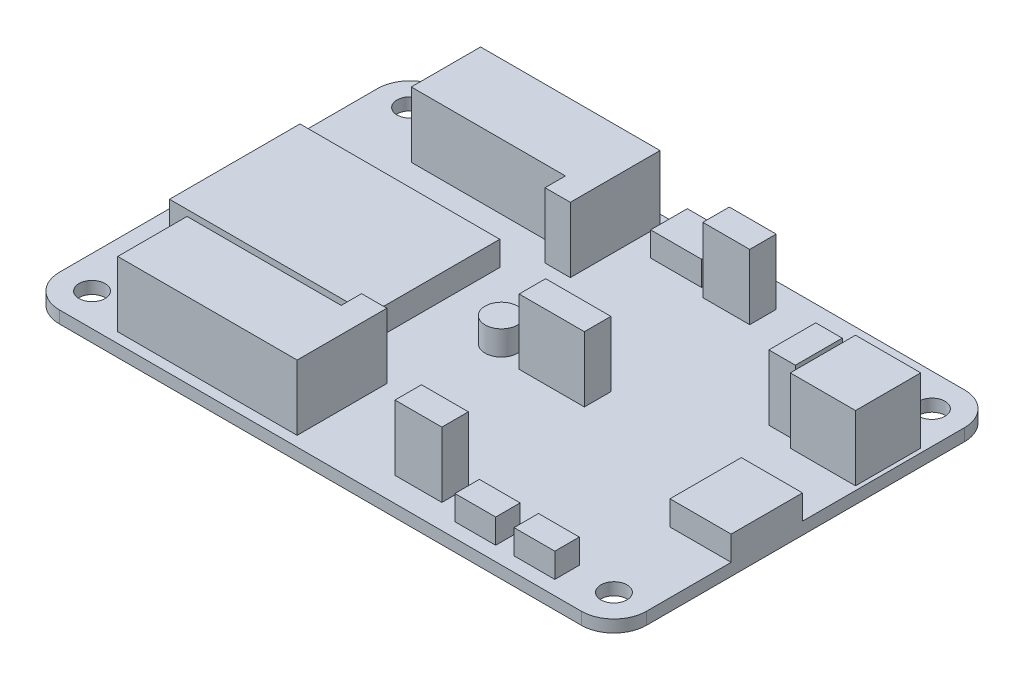
from build123d import *

# Parameters (mm, degrees)
CROQUIS1_W              = 72
CROQUIS1_H              = 47
SALIENTE_EXTRUIR1_DEPTH = 1.5
CROQUIS2_R              = 1.6
CORTAR_EXTRUIR1_DEPTH   = 2.5
REDONDEO1_R             = 4
CROQUIS3_W              = 5.75
CROQUIS3_H              = 3.25
CROQUIS3_W_2            = 3.25
CROQUIS3_H_2            = 5.75
CROQUIS3_W_3            = 8
CROQUIS3_H_3            = 8
SALIENTE_EXTRUIR2_DEPTH = 8
CROQUIS6_R              = 2
CROQUIS6_W              = 7.5
CROQUIS6_H              = 8.749690514
CROQUIS6_W_2            = 5
CROQUIS6_H_2            = 3
CROQUIS6_W_3            = 6.25
CROQUIS6_H_3            = 4.5
CROQUIS6_W_4            = 24.5
CROQUIS6_H_4            = 16
SALIENTE_EXTRUIR3_DEPTH = 3


with BuildPart() as part:
    # Croquis1 → Saliente-Extruir1 (new body)
    with BuildSketch(Plane(origin=(0, 0, 0), x_dir=(1, 0, 0), z_dir=(0, 1, 0))):
        Rectangle(CROQUIS1_W, CROQUIS1_H)
    extrude(amount=SALIENTE_EXTRUIR1_DEPTH)

    # Croquis2 → Cortar-Extruir1 (cut, through all)
    with BuildSketch(Plane(origin=(0, 1.5, 0), x_dir=(1, 0, 0), z_dir=(0, 1, 0))):
        with Locations((-32, 19.5)):
            Circle(CROQUIS2_R)
        with Locations((32, 19.5)):
            Circle(CROQUIS2_R)
        with Locations((32, -19.5)):
            Circle(CROQUIS2_R)
        with Locations((-32, -19.5)):
            Circle(CROQUIS2_R)
    extrude(amount=-CORTAR_EXTRUIR1_DEPTH, mode=Mode.SUBTRACT)

    # Redondeo1
    redondeo1_edges = [part.edges().sort_by_distance(p)[0] for p in [
        (36, 0.75, 23.5),
        (-36, 0.75, 23.5),
        (-36, 0.75, -23.5),
        (36, 0.75, -23.5),
    ]]
    fillet(redondeo1_edges, radius=REDONDEO1_R)

    # Croquis3 → Saliente-Extruir2 (add)
    with BuildSketch(Plane(origin=(0, 1.5, 0), x_dir=(1, 0, 0), z_dir=(0, 1, 0))):
        Polygon((-4.1, 11.25), (-7.2, 11.25), (-7.2, 13.75), (-26.1, 13.75), (-26.1, 22.25), (-4.1, 22.25), align=None)
        with Locations((9.025, -18.875)):
            Rectangle(CROQUIS3_W, CROQUIS3_H)
        with Locations((9.025, 18.875)):
            Rectangle(CROQUIS3_W, CROQUIS3_H)
        Polygon((-7.2, -13.75), (-26.1, -13.75), (-26.1, -22.25), (-4.1, -22.25), (-4.1, -11.25), (-7.2, -11.25), align=None)
        with Locations((25.375, 10.625)):
            Rectangle(CROQUIS3_W_2, CROQUIS3_H_2)
        with Locations((31.5, 10.625)):
            Rectangle(CROQUIS3_W_3, CROQUIS3_H_3)
        with Locations((6.5, 0)):
            Rectangle(CROQUIS3_W_3, CROQUIS3_H)
    extrude(amount=SALIENTE_EXTRUIR2_DEPTH)

    # Croquis6 → Saliente-Extruir3 (add)
    with BuildSketch(Plane(origin=(0, 1.5, 0), x_dir=(1, 0, 0), z_dir=(0, 1, 0))):
        with Locations((-1.3, 0)):
            Circle(CROQUIS6_R)
        with Locations((32.25, -4.749845257)):
            Rectangle(CROQUIS6_W, CROQUIS6_H)
        with Locations((17.248785916, -20.25)):
            Rectangle(CROQUIS6_W_2, CROQUIS6_H_2)
        with Locations((24.5, -20.25)):
            Rectangle(CROQUIS6_W_2, CROQUIS6_H_2)
        with Locations((1.875, 20.5)):
            Rectangle(CROQUIS6_W_3, CROQUIS6_H_3)
        with Locations((-21.75, 0)):
            Rectangle(CROQUIS6_W_4, CROQUIS6_H_4)
    extrude(amount=SALIENTE_EXTRUIR3_DEPTH)


solid = part.part
